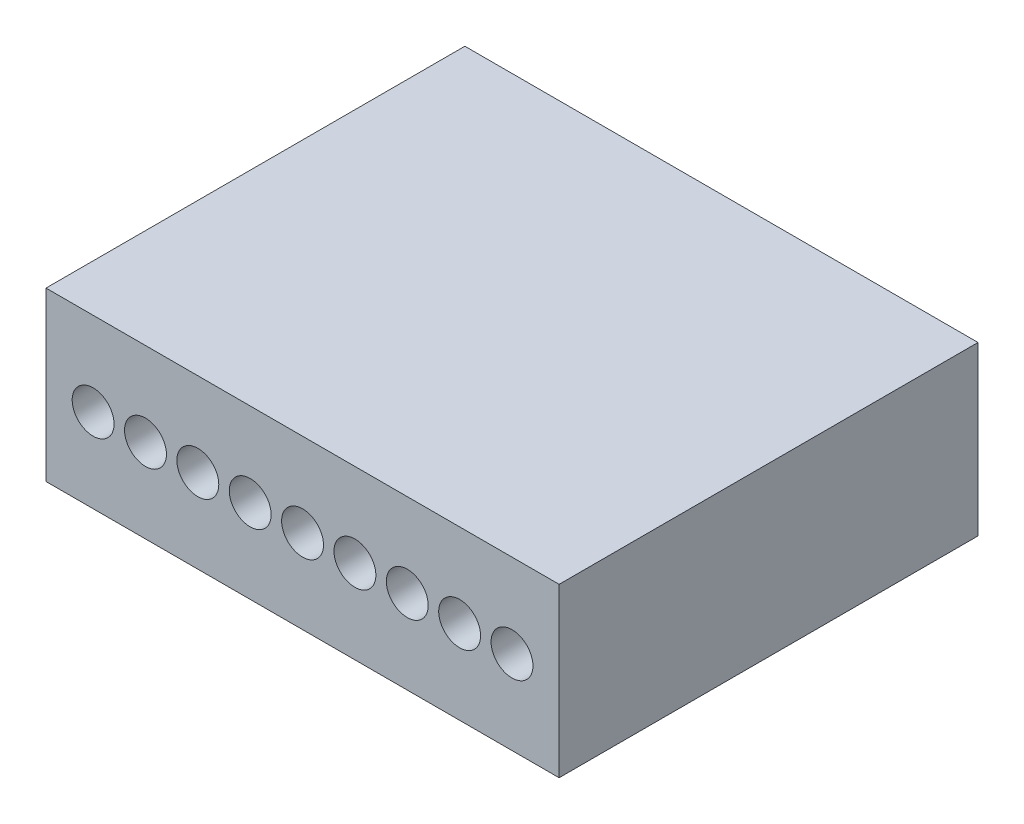
from build123d import *

# Parameters (mm, degrees)
SKETCH2_W           = 12.25
SKETCH2_H           = 4
BOSS_EXTRUDE1_DEPTH = 10
SKETCH3_R           = 0.5
CUT_EXTRUDE1_DEPTH  = 5


with BuildPart() as part:
    # Sketch2 → Boss-Extrude1 (new body)
    with BuildSketch(Plane.XY):
        with Locations((6.125, 2)):
            Rectangle(SKETCH2_W, SKETCH2_H)
    extrude(amount=BOSS_EXTRUDE1_DEPTH)

    # Sketch3 → Cut-Extrude1 (cut)
    with BuildSketch(Plane.XY.offset(10)):
        with Locations((1.125, 2)):
            Circle(SKETCH3_R)
        with Locations((2.375, 2)):
            Circle(SKETCH3_R)
        with Locations((3.625, 2)):
            Circle(SKETCH3_R)
        with Locations((4.875, 2)):
            Circle(SKETCH3_R)
        with Locations((6.125, 2)):
            Circle(SKETCH3_R)
        with Locations((7.375, 2)):
            Circle(SKETCH3_R)
        with Locations((8.625, 2)):
            Circle(SKETCH3_R)
        with Locations((9.875, 2)):
            Circle(SKETCH3_R)
        with Locations((11.125, 2)):
            Circle(SKETCH3_R)
    extrude(amount=-CUT_EXTRUDE1_DEPTH, mode=Mode.SUBTRACT)


solid = part.part
